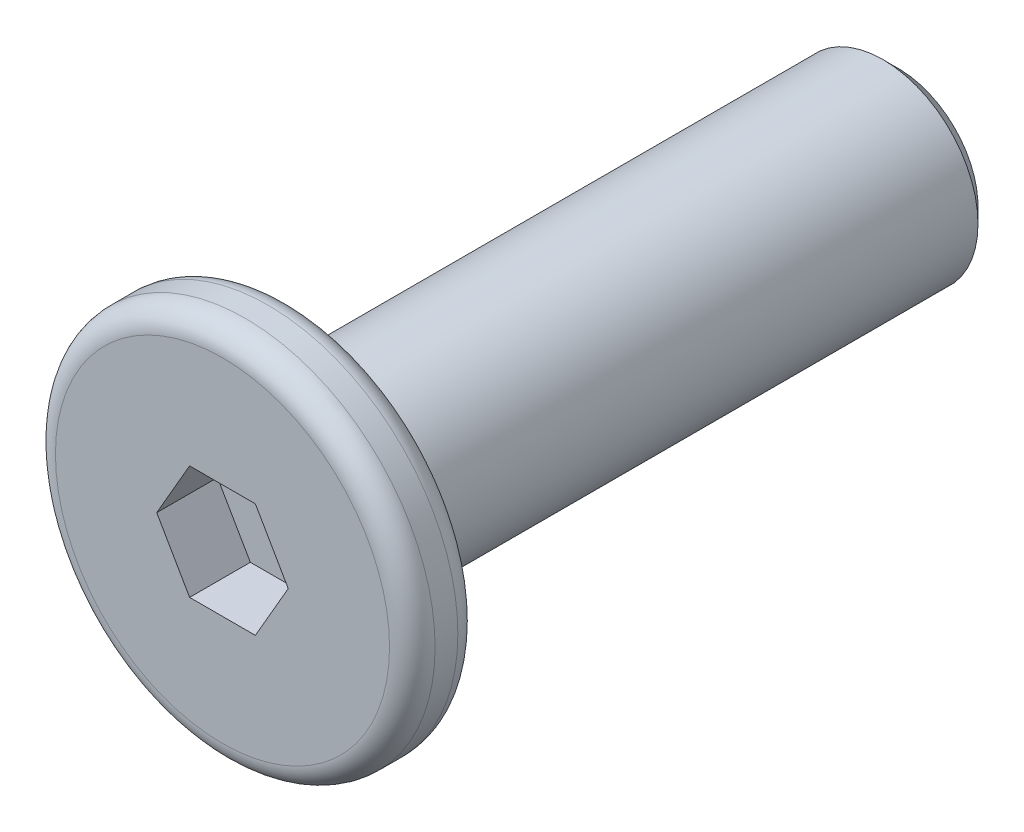
from build123d import *

# Parameters (mm, degrees)
SKETCH_1_R          = 2.5
EXTRUDE_1_DEPTH     = 0.45
SKETCH_2_R          = 1.25
EXTRUDE_2_DEPTH     = 8
CHAMFER_1_SIZE      = 0.2
CUT_EXTRUDE_1_DEPTH = 0.8
FILLET_2_R          = 0.3


with BuildPart() as part:
    # 草图1 → 凸台-拉伸1 (new body, symmetric)
    with BuildSketch(Plane.XY):
        Circle(SKETCH_1_R)
    extrude(amount=EXTRUDE_1_DEPTH, both=True)

    # 草图2 → 凸台-拉伸2 (add)
    with BuildSketch(Plane(origin=(0, 0, -0.45), x_dir=(-1, 0, 0), z_dir=(0, 0, -1))):
        Circle(SKETCH_2_R)
    extrude(amount=EXTRUDE_2_DEPTH)

    # 倒角1
    chamfer_1_edges = [part.edges().sort_by_distance(p)[0] for p in [
        (1.25, 0, -8.45),
    ]]
    chamfer(chamfer_1_edges, length=CHAMFER_1_SIZE)

    # 草图3 → 切除-拉伸1 (cut)
    with BuildSketch(Plane.XY.offset(0.45)):
        Polygon((0.866025404, 0), (0.433012702, 0.75), (-0.433012702, 0.75), (-0.866025404, 0), (-0.433012702, -0.75), (0.433012702, -0.75), align=None)
    extrude(amount=-CUT_EXTRUDE_1_DEPTH, mode=Mode.SUBTRACT)

    # 圆角2
    fillet_2_edges = [part.edges().sort_by_distance(p)[0] for p in [
        (-2.5, 0, -0.45),
        (-2.5, 0, 0.45),
    ]]
    fillet(fillet_2_edges, radius=FILLET_2_R)


solid = part.part
